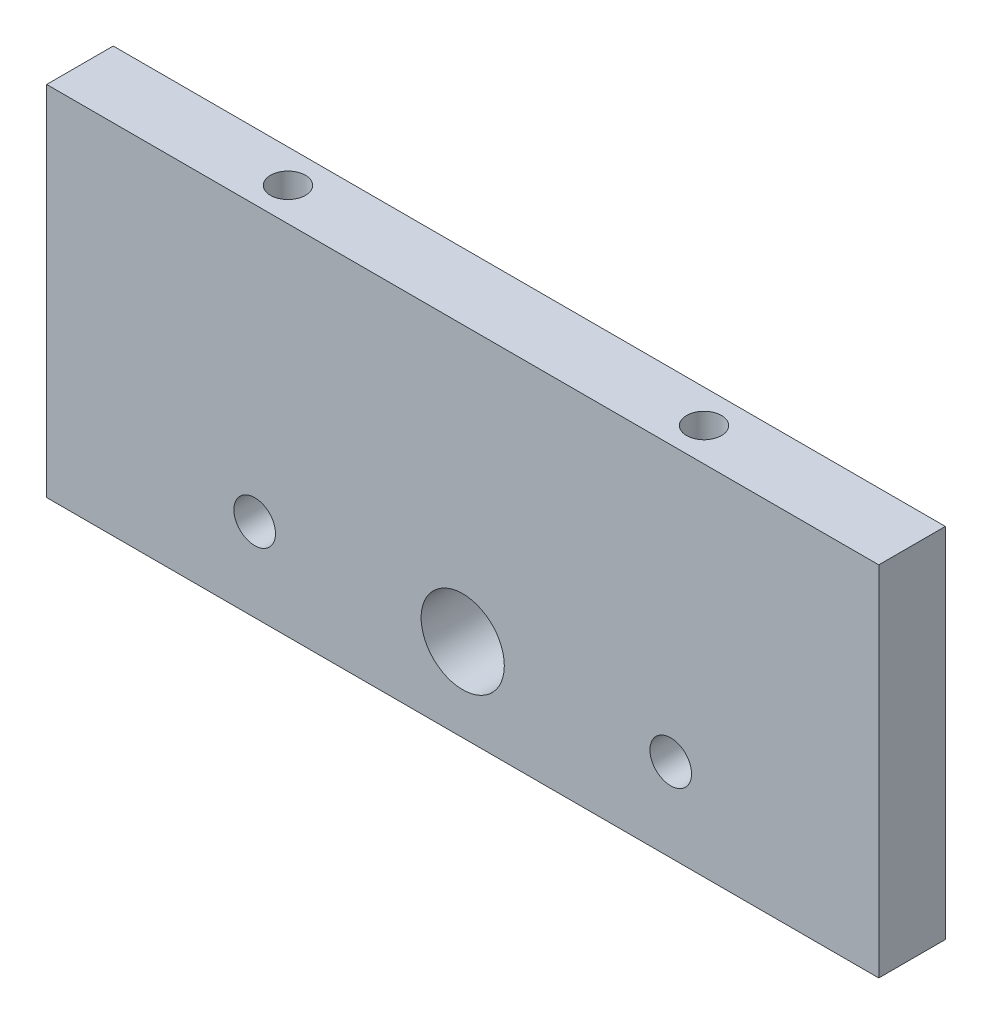
from build123d import *

# Parameters (mm, degrees)
SKETCH_2_W             = 100
SKETCH_2_H             = 43
EXTRUDE_1_DEPTH        = 8
SKETCH_3_R             = 5
CUT_EXTRUDE_1_DEPTH    = 8
HOLE_WIZARD_M6_1_D     = 5
HOLE_WIZARD_M6_1_DEPTH = 15
HOLE_WIZARD_M6_1_TIP   = 1.502151548
HOLE_WIZARD_M5_1_D     = 4.2
HOLE_WIZARD_M5_1_DEPTH = 12.4
HOLE_WIZARD_M5_1_TIP   = 1.2618073


with BuildPart() as part:
    # 草图2 → 凸台-拉伸1 (new body)
    with BuildSketch(Plane.XY):
        with Locations((50, 21.5)):
            Rectangle(SKETCH_2_W, SKETCH_2_H)
    extrude(amount=EXTRUDE_1_DEPTH)

    # 草图3 → 切除-拉伸1 (cut)
    with BuildSketch(Plane.XY.offset(8)):
        with Locations((50, 10)):
            Circle(SKETCH_3_R)
    extrude(amount=-CUT_EXTRUDE_1_DEPTH, mode=Mode.SUBTRACT)

    # M6 螺纹孔1
    with Locations(Plane.XY.offset(8)):
        with Locations((25, 10), (75, 10)):
            Hole(HOLE_WIZARD_M6_1_D / 2, depth=HOLE_WIZARD_M6_1_DEPTH)
            with Locations((0, 0, -(HOLE_WIZARD_M6_1_DEPTH + HOLE_WIZARD_M6_1_TIP / 2))):  # 118° drill point
                Cone(0, HOLE_WIZARD_M6_1_D / 2, HOLE_WIZARD_M6_1_TIP, mode=Mode.SUBTRACT)

    # M5 螺纹孔1
    with Locations(Plane(origin=(0, 43, 0), x_dir=(1, 0, 0), z_dir=(0, 1, 0))):
        with Locations((25, -4), (75, -4)):
            Hole(HOLE_WIZARD_M5_1_D / 2, depth=HOLE_WIZARD_M5_1_DEPTH)
            with Locations((0, 0, -(HOLE_WIZARD_M5_1_DEPTH + HOLE_WIZARD_M5_1_TIP / 2))):  # 118° drill point
                Cone(0, HOLE_WIZARD_M5_1_D / 2, HOLE_WIZARD_M5_1_TIP, mode=Mode.SUBTRACT)


solid = part.part
